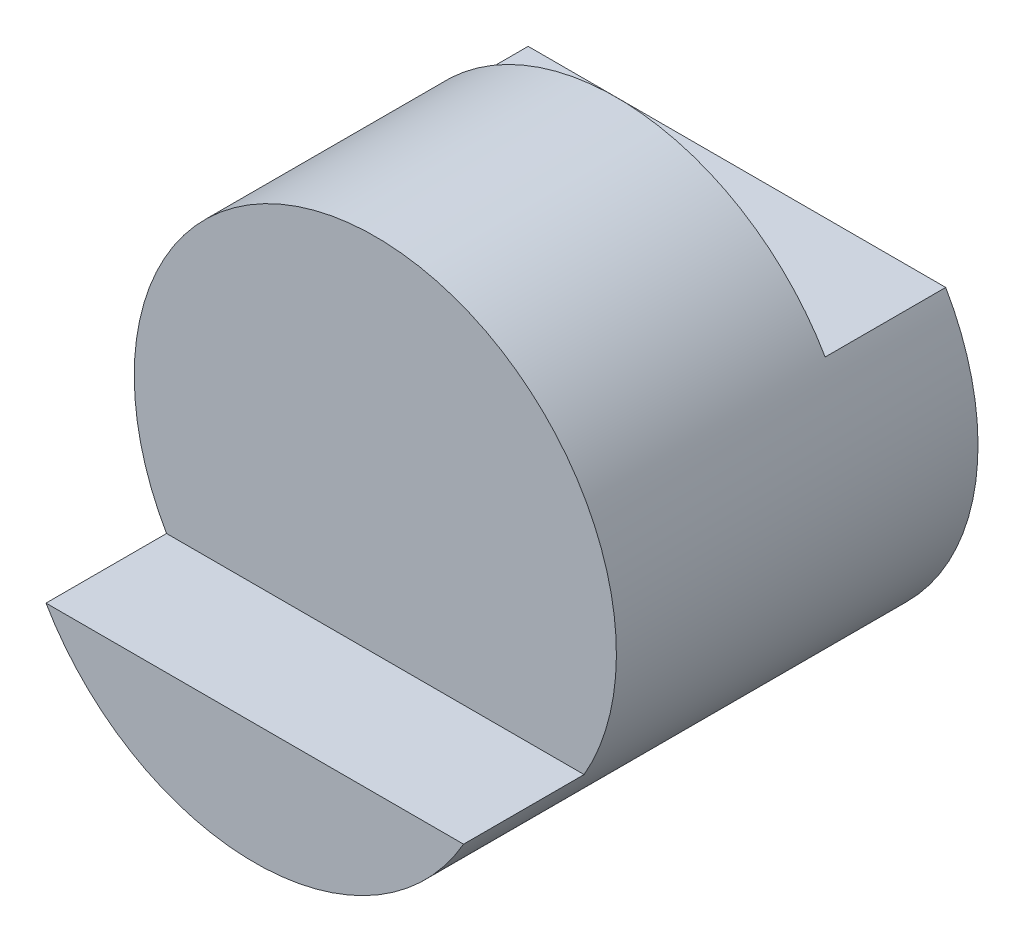
from build123d import *

# Parameters (mm, degrees)
SKETCH1_R           = 2
BOSS_EXTRUDE1_DEPTH = 3
BOSS_EXTRUDE2_DEPTH = 1
CUT_EXTRUDE1_DEPTH  = 1


with BuildPart() as part:
    # Sketch1 → Boss-Extrude1 (new body)
    with BuildSketch(Plane.XY):
        Circle(SKETCH1_R)
    extrude(amount=BOSS_EXTRUDE1_DEPTH)

    # Sketch2 → Boss-Extrude2 (add)
    with BuildSketch(Plane.XY.offset(3)):
        with BuildLine():
            Line((-1.732050808, -1), (1.732050808, -1))
            ThreePointArc((1.732050808, -1), (0, -2), (-1.732050808, -1))
        make_face()
    extrude(amount=BOSS_EXTRUDE2_DEPTH)

    # Sketch3 → Cut-Extrude1 (cut)
    with BuildSketch(Plane(origin=(0, 0, 0), x_dir=(-1, 0, 0), z_dir=(0, 0, -1))):
        with BuildLine():
            Line((1.732050808, 1), (-1.732050808, 1))
            ThreePointArc((-1.732050808, 1), (0, 2), (1.732050808, 1))
        make_face()
    extrude(amount=-CUT_EXTRUDE1_DEPTH, mode=Mode.SUBTRACT)


solid = part.part
